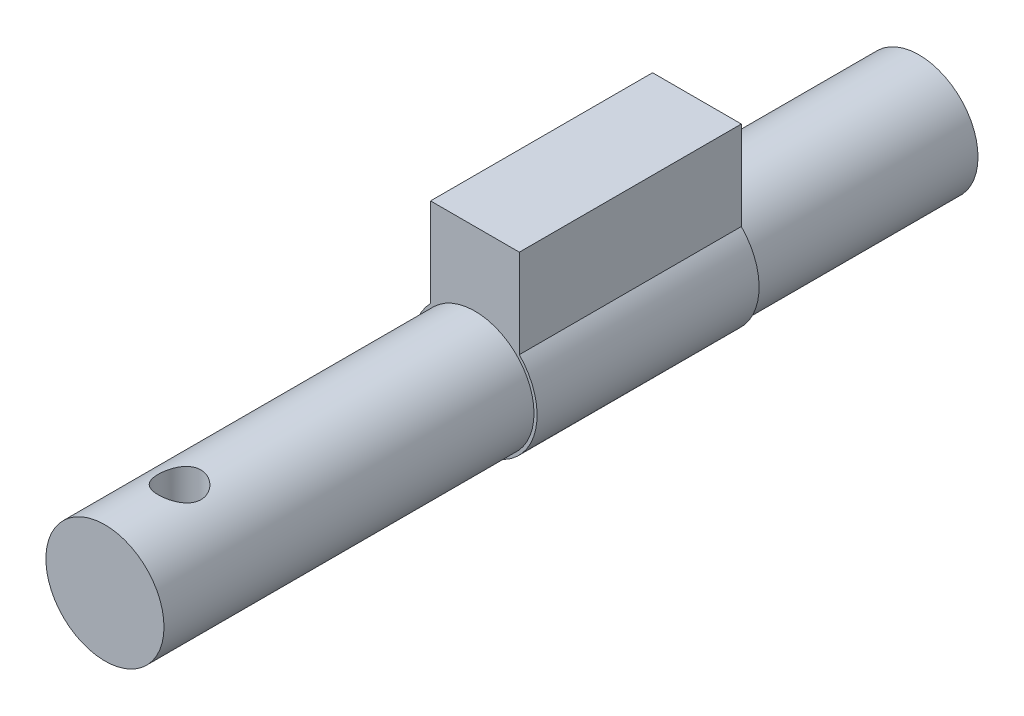
from build123d import *

# Parameters (mm, degrees)
SKETCH1_R           = 3.99
BOSS_EXTRUDE1_DEPTH = 15
BOSS_EXTRUDE7_DEPTH = 15
SKETCH7_R           = 3.99
BOSS_EXTRUDE8_DEPTH = 25
SKETCH8_R           = 1.45
CUT_EXTRUDE1_DEPTH  = 8


with BuildPart() as part:
    # Sketch1 → Boss-Extrude1 (new body)
    with BuildSketch(Plane.XY):
        with Locations((-14.383915809, -0.854852817)):
            Circle(SKETCH1_R)
    extrude(amount=BOSS_EXTRUDE1_DEPTH)

    # Sketch6 → Boss-Extrude7 (add)
    with BuildSketch(Plane.XY.offset(15)):
        with BuildLine():
            Line((-17.383915809, 2.084534875), (-17.383915809, 8.084534875))
            Line((-17.383915809, 8.084534875), (-11.383915809, 8.084534875))
            Line((-11.383915809, 8.084534875), (-11.383915809, 2.084534875))
            ThreePointArc((-11.383915809, 2.084534875), (-14.383915809, -5.054852817), (-17.383915809, 2.084534875))
        make_face()
    extrude(amount=BOSS_EXTRUDE7_DEPTH)

    # Sketch7 → Boss-Extrude8 (add)
    with BuildSketch(Plane.XY.offset(30)):
        with Locations((-14.383915809, -0.854852817)):
            Circle(SKETCH7_R)
    extrude(amount=BOSS_EXTRUDE8_DEPTH)

    # Sketch8 → Cut-Extrude1 (cut)
    with BuildSketch(Plane(origin=(0, 8.084534875, 0), x_dir=(1, 0, 0), z_dir=(0, 1, 0))):
        with Locations((-14.343915809, -50)):
            Circle(SKETCH8_R)
    extrude(amount=-CUT_EXTRUDE1_DEPTH, mode=Mode.SUBTRACT)


solid = part.part
